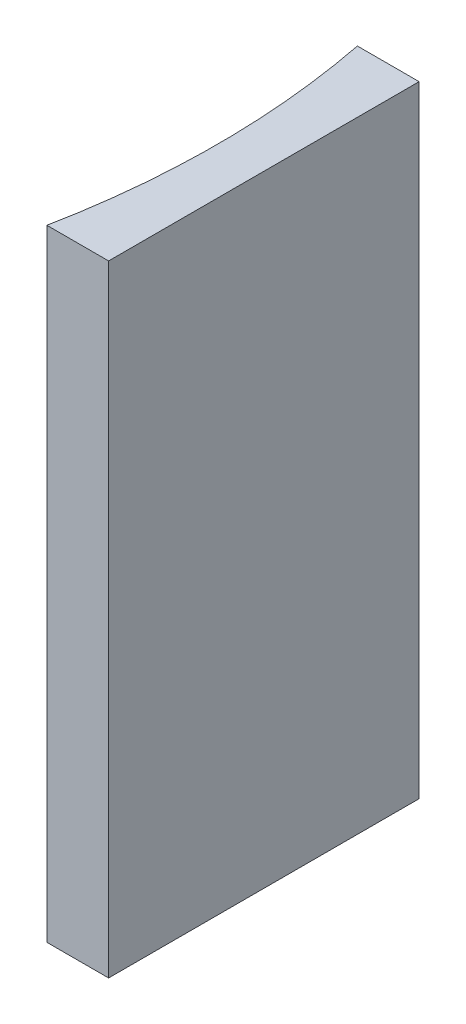
from build123d import *

# Parameters (mm, degrees)
EXTRUDE_1_DEPTH = 40


with BuildPart() as part:
    # 草图1 → 凸台-拉伸1 (new body)
    with BuildSketch(Plane(origin=(0, 0, 0), x_dir=(1, 0, 0), z_dir=(0, 1, 0))):
        with BuildLine():
            Line((0, 0), (0, -20))
            Line((0, -20), (-3.976721999, -20))
            ThreePointArc((-3.976721999, -20), (-3, -10), (-3.976721999, 0))
            Line((-3.976721999, 0), (0, 0))
        make_face()
    extrude(amount=EXTRUDE_1_DEPTH)


solid = part.part
